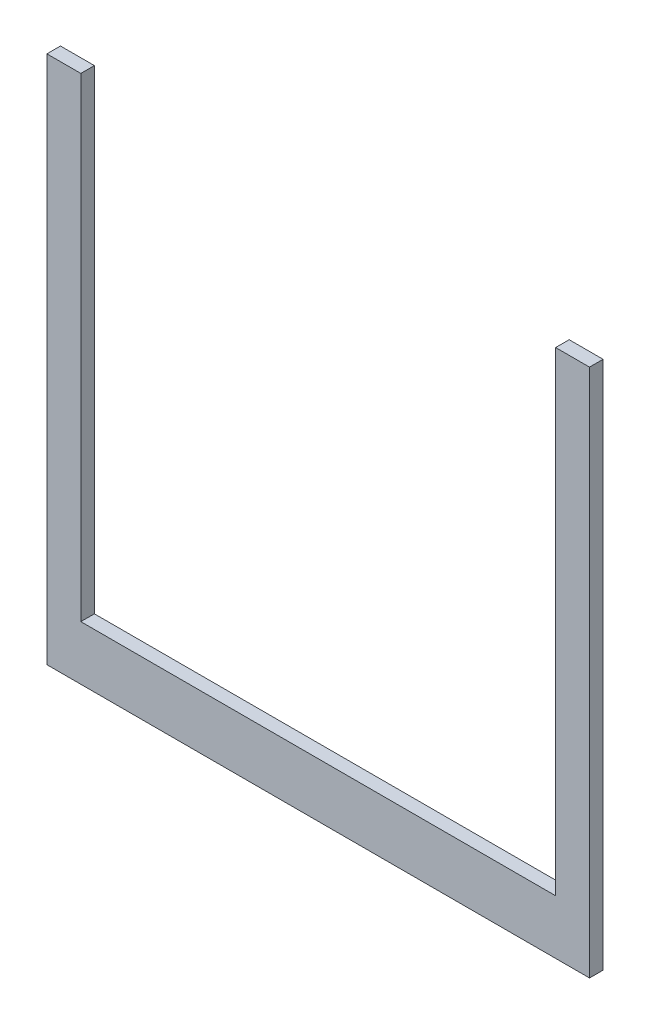
from build123d import *

# Parameters (mm, degrees)
BOSS_EXTRUDE1_DEPTH = 10


with BuildPart() as part:
    # Sketch1 → Boss-Extrude1 (new body)
    with BuildSketch(Plane.XY):
        Polygon((0, 390), (25, 390), (25, 40), (375, 40), (375, 390), (400, 390), (400, 0), (0, 0), align=None)
    extrude(amount=BOSS_EXTRUDE1_DEPTH)


solid = part.part
